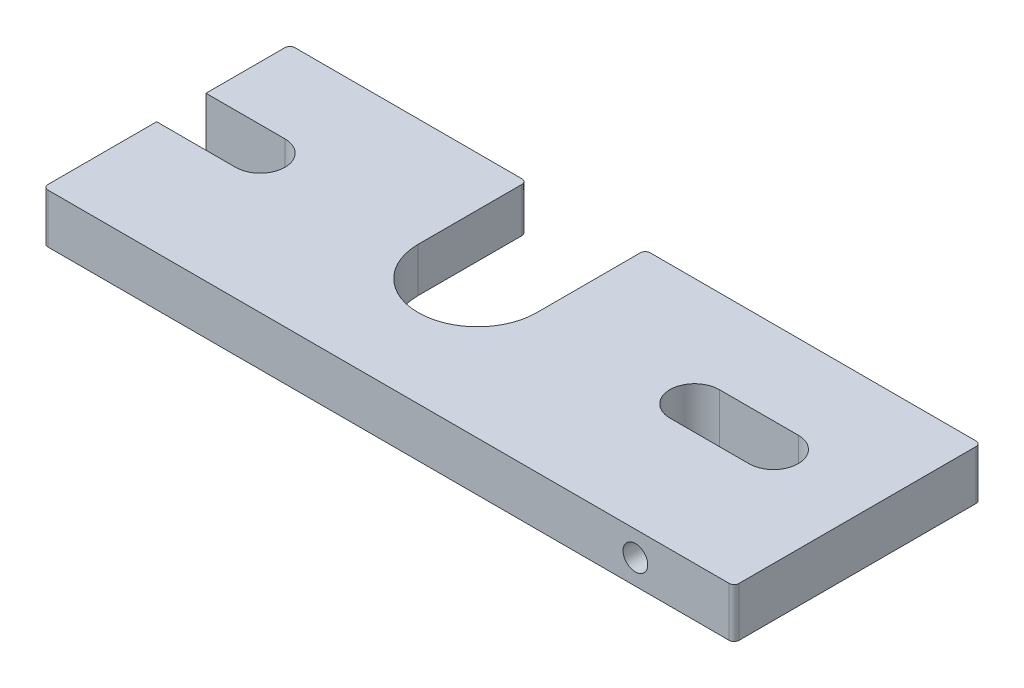
from build123d import *

# Parameters (mm, degrees)
BOSS_EXTRUDE1_DEPTH       = 5
CUT_EXTRUDE1_DEPTH        = 0.5
CUT_EXTRUDE2_DEPTH        = 3
M3X0_5_TAPPED_HOLE1_D     = 2.5
M3X0_5_TAPPED_HOLE1_DEPTH = 7.5
M3X0_5_TAPPED_HOLE1_TIP   = 0.751075774
FILLET1_R                 = 0.5


with BuildPart() as part:
    # Sketch1 → Boss-Extrude1 (new body)
    with BuildSketch(Plane(origin=(0, 0, 0), x_dir=(1, 0, 0), z_dir=(0, 1, 0))):
        with BuildLine():
            Line((-30, 11), (-6, 11))
            Line((-6, 11), (-6, 0))
            ThreePointArc((-6, 0), (0, -6), (6, 0))
            Line((6, 0), (6, 11))
            Line((6, 11), (40, 11))
            Line((40, 11), (40, -14))
            Line((40, -14), (-30, -14))
            Line((-30, -14), (-30, -2.5))
            Line((-30, -2.5), (-22, -2.5))
            ThreePointArc((-22, -2.5), (-19.5, 0), (-22, 2.5))
            Line((-22, 2.5), (-30, 2.5))
            Line((-30, 2.5), (-30, 11))
        make_face()
        with BuildLine():
            Line((22, 2.5), (30, 2.5))
            ThreePointArc((30, 2.5), (32.5, 0), (30, -2.5))
            Line((30, -2.5), (22, -2.5))
            ThreePointArc((22, -2.5), (19.5, 0), (22, 2.5))
        make_face(mode=Mode.SUBTRACT)
    extrude(amount=BOSS_EXTRUDE1_DEPTH)

    # Sketch2 → Cut-Extrude1 (cut)
    with BuildSketch(Plane.XZ):
        with BuildLine():
            Line((-9, 0), (-9, -11))
            Line((-9, -11), (9, -11))
            Line((9, -11), (9, 0))
            ThreePointArc((9, 0), (0, 9), (-9, 0))
        make_face()
    extrude(amount=-CUT_EXTRUDE1_DEPTH, mode=Mode.SUBTRACT)

    # Sketch3 → Cut-Extrude2 (cut)
    with BuildSketch(Plane.XZ):
        with BuildLine():
            Line((-11, 8), (-11, -5))
            ThreePointArc((-11, -5), (-14, -8), (-17, -5))
            Line((-17, -5), (-17, 8))
            ThreePointArc((-17, 8), (-14, 11), (-11, 8))
        make_face()
        with BuildLine():
            Line((18, 8), (18, -5))
            ThreePointArc((18, -5), (14.5, -8.5), (11, -5))
            Line((11, -5), (11, 8))
            ThreePointArc((11, 8), (14.5, 11.5), (18, 8))
        make_face()
        with BuildLine():
            Line((38.85, 7.5), (38.85, -5))
            ThreePointArc((38.85, -5), (36.35, -7.5), (33.85, -5))
            Line((33.85, -5), (33.85, 7.5))
            ThreePointArc((33.85, 7.5), (36.35, 10), (38.85, 7.5))
        make_face()
    extrude(amount=-CUT_EXTRUDE2_DEPTH, mode=Mode.SUBTRACT)

    # M3x0.5 Tapped Hole1
    with Locations(Plane.XY.offset(14)):
        with Locations((30, 2.5)):
            Hole(M3X0_5_TAPPED_HOLE1_D / 2, depth=M3X0_5_TAPPED_HOLE1_DEPTH)
            with Locations((0, 0, -(M3X0_5_TAPPED_HOLE1_DEPTH + M3X0_5_TAPPED_HOLE1_TIP / 2))):  # 118° drill point
                Cone(0, M3X0_5_TAPPED_HOLE1_D / 2, M3X0_5_TAPPED_HOLE1_TIP, mode=Mode.SUBTRACT)

    # Fillet1
    fillet1_edges = [part.edges().sort_by_distance(p)[0] for p in [
        (40, 2.5, -11),
        (40, 2.5, 14),
        (-30, 2.5, 14),
        (-30, 2.5, -11),
        (-6, 2.75, -11),
        (6, 2.75, -11),
    ]]
    fillet(fillet1_edges, radius=FILLET1_R)


solid = part.part
